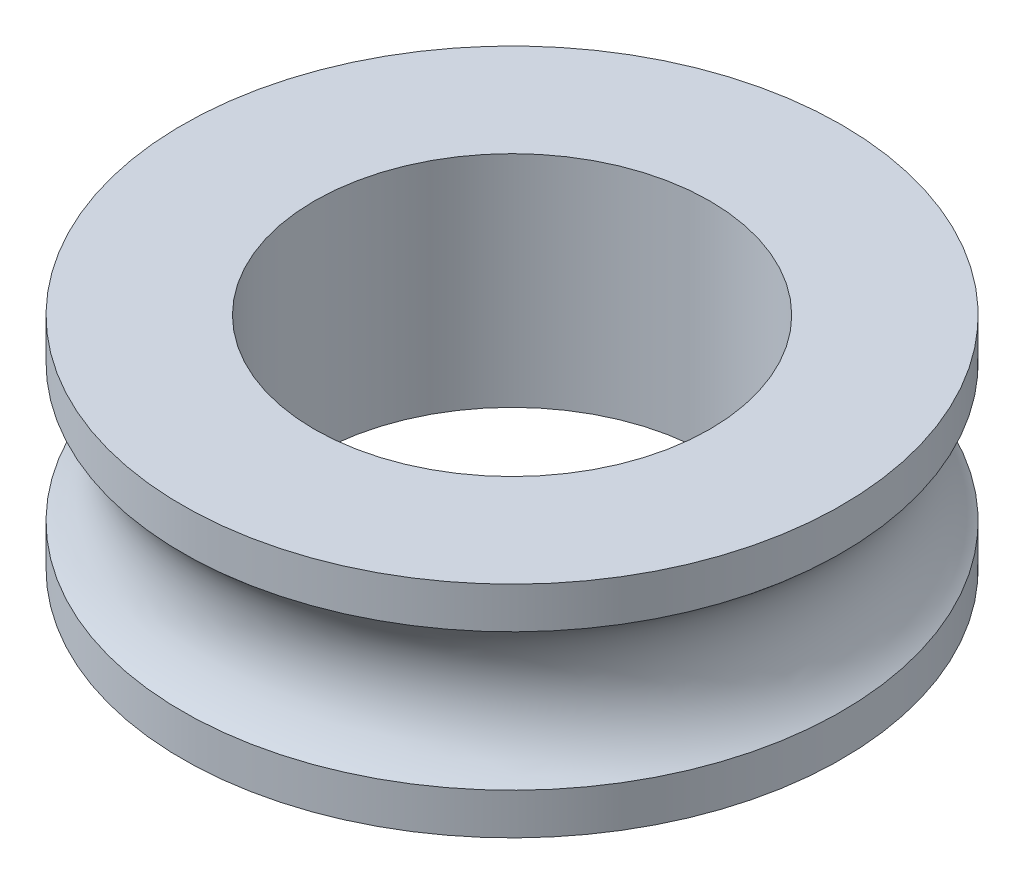
from build123d import *

# Parameters (mm, degrees)
IZIM2_R               = 0.9
KES_EKSTR_ZYON1_DEPTH = 1


with BuildPart() as part:
    # Çizim1 → Döndür1 (revolve)
    with BuildSketch(Plane.XY):
        with BuildLine():
            Line((0, 0), (0, 0.5))
            Line((0, 0.5), (1.5, 0.5))
            Line((1.5, 0.5), (1.5, 0.3122499))
            ThreePointArc((1.5, 0.3122499), (1.35, 0), (1.5, -0.3122499))
            Line((1.5, -0.3122499), (1.5, -0.5))
            Line((1.5, -0.5), (0, -0.5))
            Line((0, -0.5), (0, 0))
        make_face()
    revolve(axis=Axis((0, 0, 0), (0, 1, 0)))

    # Çizim2 → Kes-Ekstrüzyon1 (cut)
    with BuildSketch(Plane(origin=(0, 0.5, 0), x_dir=(1, 0, 0), z_dir=(0, 1, 0))):
        Circle(IZIM2_R)
    extrude(amount=-KES_EKSTR_ZYON1_DEPTH, mode=Mode.SUBTRACT)


solid = part.part
